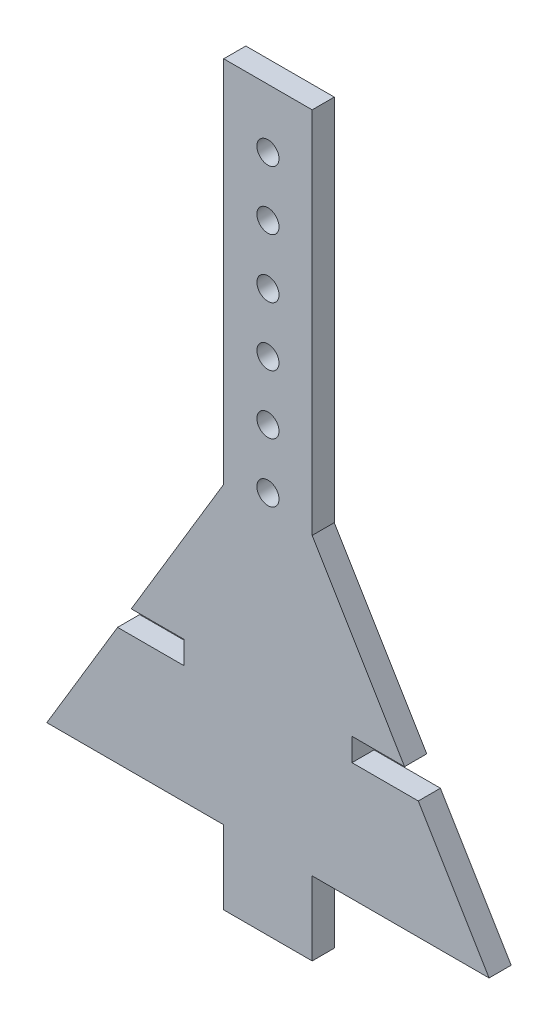
from build123d import *

# Parameters (mm, degrees)
ESQUISSE1_R             = 7.5
BOSS_EXTRU_1_DEPTH      = 15
ESQUISSE2_W             = 90.989913166
ESQUISSE2_H             = 15.5
ENL_V_MAT_EXTRU_1_DEPTH = 15


with BuildPart() as part:
    # Esquisse1 → Boss.-Extru.1 (new body)
    with BuildSketch(Plane.XY):
        Polygon((-30, 0), (-150, -200), (-30, -200), (-30, -250), (30, -250), (30, -200), (150, -200), (30, 0), (30, 250), (-30, 250), align=None)
        with Locations((0, 210)):
            Circle(ESQUISSE1_R, mode=Mode.SUBTRACT)
        with Locations((0, 170)):
            Circle(ESQUISSE1_R, mode=Mode.SUBTRACT)
        with Locations((0, 130)):
            Circle(ESQUISSE1_R, mode=Mode.SUBTRACT)
        with Locations((0, 90)):
            Circle(ESQUISSE1_R, mode=Mode.SUBTRACT)
        with Locations((0, 50)):
            Circle(ESQUISSE1_R, mode=Mode.SUBTRACT)
        with Locations((0, 10)):
            Circle(ESQUISSE1_R, mode=Mode.SUBTRACT)
    extrude(amount=BOSS_EXTRU_1_DEPTH)

    # Esquisse2 → Enlèv. mat.-Extru.1 (cut)
    with BuildSketch(Plane.XY.offset(15)):
        with Locations((-102.494956583, -112.25)):
            Rectangle(ESQUISSE2_W, ESQUISSE2_H)
    enl_v_mat_extru_1 = extrude(amount=-ENL_V_MAT_EXTRU_1_DEPTH, mode=Mode.SUBTRACT)

    # Symétrie1: Enlèv. mat.-Extru.1 across plane
    add(enl_v_mat_extru_1.mirror(Plane(origin=(0, 0, 0), x_dir=(0, 0, 1), z_dir=(1, 0, 0))), mode=Mode.SUBTRACT)


solid = part.part
